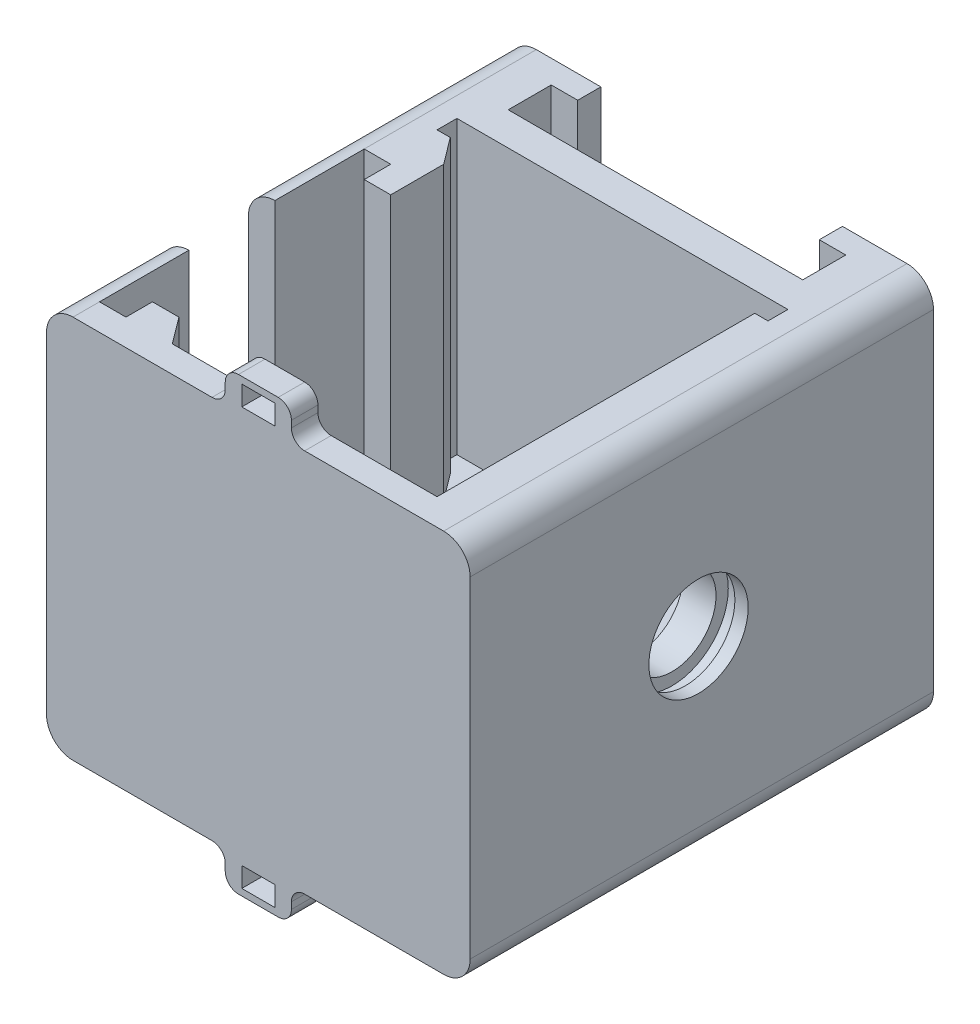
from build123d import *

# Parameters (mm, degrees)
SKETCH1_W                = 32
SKETCH1_H                = 29
BOSS_EXTRUDE1_DEPTH      = 35
FILLET1_R                = 2
SLOT_FOR_COIL_DEPTH      = 1
SLOT_FOR_COIL_DEPTH_BACK = 30
BOSS_EXTRUDE2_DEPTH      = 7
BOSS_EXTRUDE3_DEPTH      = 1.75
SKETCH5_W                = 2
SKETCH5_H                = 7
CUT_EXTRUDE2_DEPTH       = 33
CUT_EXTRUDE3_DEPTH       = 22
SKETCH7_W                = 2
SKETCH7_H                = 33
BOSS_EXTRUDE4_DEPTH      = 0.25
FILLET2_R                = 6
CUT_EXTRUDE5_DEPTH       = 4.5
SKETCH14_W               = 2.5
SKETCH14_H               = 20
CUT_EXTRUDE6_DEPTH       = 22
SKETCH16_W               = 2
SKETCH16_H               = 4
SKETCH16_H_2             = 2
BOSS_EXTRUDE5_DEPTH      = 22
BOSS_EXTRUDE6_DEPTH      = 22
SKETCH21_W               = 5
SKETCH21_H               = 2
BOSS_EXTRUDE7_DEPTH      = 2.5
SKETCH23_W               = 2.5
SKETCH23_H               = 1.5
CUT_EXTRUDE7_DEPTH       = 2
FILLET3_R                = 1


with BuildPart() as part:
    # Sketch1 → Boss-Extrude1 (new body)
    with BuildSketch(Plane.XY):
        Rectangle(SKETCH1_W, SKETCH1_H)
    extrude(amount=BOSS_EXTRUDE1_DEPTH)

    # Fillet1
    fillet1_edges = [part.edges().sort_by_distance(p)[0] for p in [
        (16, -14.5, 17.5),
        (-16, -14.5, 17.5),
        (-16, 14.5, 17.5),
        (16, 14.5, 17.5),
    ]]
    fillet(fillet1_edges, radius=FILLET1_R)

    # Sketch2 → Slot for Coil (cut, two sides)
    with BuildSketch(Plane.XZ.offset(14.5)) as slot_for_coil_sk:
        Polygon((-9.125, 0), (-9.125, 1.75), (-11.125, 1.75), (-11.125, 5), (11.125, 5), (11.125, 1.75), (9.125, 1.75), (9.125, 0), align=None)
    extrude(amount=SLOT_FOR_COIL_DEPTH, mode=Mode.SUBTRACT)
    extrude(slot_for_coil_sk.sketch, amount=-SLOT_FOR_COIL_DEPTH_BACK, mode=Mode.SUBTRACT)

    # Sketch3 → Boss-Extrude2 (add)
    with BuildSketch(Plane.XZ.offset(14.5)):
        Polygon((-9.125, 0), (-9.125, 1.75), (-11.125, 1.75), (-11.125, 5), (11.125, 5), (11.125, 1.75), (9.125, 1.75), (9.125, 0), align=None)
    extrude(amount=-BOSS_EXTRUDE2_DEPTH)

    # Sketch4 → Boss-Extrude3 (add)
    with BuildSketch(Plane(origin=(0, 0, 1.75), x_dir=(-1, 0, 0), z_dir=(0, 0, -1))):
        with BuildLine():
            Line((-9.125, 7.5), (-9.125, 6.5))
            ThreePointArc((-9.125, 6.5), (-8.875, 7), (-9.125, 7.5))
        make_face()
    boss_extrude3 = extrude(amount=BOSS_EXTRUDE3_DEPTH)

    # Mirror1: Boss-Extrude3 across plane
    add(boss_extrude3.mirror(Plane(origin=(0, 0, 0), x_dir=(0, 0, 1), z_dir=(1, 0, 0))))

    # Sketch5 → Cut-Extrude2 (cut)
    with BuildSketch(Plane(origin=(0, 0, 0), x_dir=(-1, 0, 0), z_dir=(0, 0, -1))):
        with Locations((0, -11)):
            Rectangle(SKETCH5_W, SKETCH5_H)
    extrude(amount=-CUT_EXTRUDE2_DEPTH, mode=Mode.SUBTRACT)

    # Sketch6 → Cut-Extrude3 (cut)
    with BuildSketch(Plane(origin=(0, 14.5, 0), x_dir=(1, 0, 0), z_dir=(0, 1, 0))):
        Polygon((-12.5, -7.5), (-12.5, -9), (-11.5, -9), (-11.5, -33), (11.5, -33), (11.5, -9), (12.5, -9), (12.5, -7.5), align=None)
    extrude(amount=-CUT_EXTRUDE3_DEPTH, mode=Mode.SUBTRACT)

    # Sketch7 → Boss-Extrude4 (add)
    with BuildSketch(Plane.XZ.offset(14.5)):
        with Locations((0, 16.5)):
            Rectangle(SKETCH7_W, SKETCH7_H)
    extrude(amount=-BOSS_EXTRUDE4_DEPTH)

    # Fillet2
    fillet2_edges = [part.edges().sort_by_distance(p)[0] for p in [
        (0, -14.25, 33),
    ]]
    fillet(fillet2_edges, radius=FILLET2_R)

    # Sketch9 → Cut-Revolve1 (revolve, cut)
    with BuildSketch(Plane(origin=(0, 0, 17.75), x_dir=(-1, 0, 0), z_dir=(0, 0, -1))):
        Polygon((-15, 4.25), (-14, 4.25), (-14, 3.325), (-11.5, 3.325), (-11.5, 0), (-16, 0), (-16, 3.75), (-15, 3.75), align=None)
    revolve(axis=Axis((16, 0, 17.75), (-1, 0, 0)), mode=Mode.SUBTRACT)

    # Sketch11 → Cut-Extrude5 (cut)
    with BuildSketch(Plane(origin=(-16, 0, 44), x_dir=(0, 0, -1), z_dir=(1, 0, 0))):
        with BuildLine():
            Line((24.25, 25), (24.25, 0))
            ThreePointArc((24.25, 0), (21, -3.25), (17.75, 0))
            Line((17.75, 0), (17.75, 25))
            ThreePointArc((17.75, 25), (21, 28.25), (24.25, 25))
        make_face()
    extrude(amount=CUT_EXTRUDE5_DEPTH, mode=Mode.SUBTRACT)

    # Sketch14 → Cut-Extrude6 (cut)
    with BuildSketch(Plane(origin=(0, 14.5, 0), x_dir=(1, 0, 0), z_dir=(0, 1, 0))):
        with Locations((-12.75, -23)):
            Rectangle(SKETCH14_W, SKETCH14_H)
    extrude(amount=-CUT_EXTRUDE6_DEPTH, mode=Mode.SUBTRACT)

    # Sketch16 → Boss-Extrude5 (add)
    with BuildSketch(Plane(origin=(0, 14.5, 0), x_dir=(1, 0, 0), z_dir=(0, 1, 0))):
        with Locations((-11, -13)):
            Rectangle(SKETCH16_W, SKETCH16_H)
        with Locations((-11, -32)):
            Rectangle(SKETCH16_W, SKETCH16_H_2)
    extrude(amount=-BOSS_EXTRUDE5_DEPTH)

    # Sketch20 → Boss-Extrude6 (add)
    with BuildSketch(Plane(origin=(0, 14.5, 0), x_dir=(1, 0, 0), z_dir=(0, 1, 0))):
        Polygon((-11.5, -9), (-10, -11), (-11.5, -11), align=None)
        Polygon((-10, -31), (-8.5, -33), (-10, -33), align=None)
    extrude(amount=-BOSS_EXTRUDE6_DEPTH)

    # Sketch21 → Boss-Extrude7 (add)
    with BuildSketch(Plane(origin=(0, 14.5, 0), x_dir=(-1, 0, 0), z_dir=(0, 1, 0))):
        with Locations((0, 34)):
            Rectangle(SKETCH21_W, SKETCH21_H)
    boss_extrude7 = extrude(amount=BOSS_EXTRUDE7_DEPTH)

    # Sketch23 → Cut-Extrude7 (cut)
    with BuildSketch(Plane.XY.offset(35)):
        with Locations((0, 15.75)):
            Rectangle(SKETCH23_W, SKETCH23_H)
    cut_extrude7 = extrude(amount=-CUT_EXTRUDE7_DEPTH, mode=Mode.SUBTRACT)

    # Mirror3: Boss-Extrude7, Cut-Extrude7 across plane
    add(boss_extrude7.mirror(Plane.ZX))
    add(cut_extrude7.mirror(Plane.ZX), mode=Mode.SUBTRACT)

    # Fillet3
    fillet3_edges = [part.edges().sort_by_distance(p)[0] for p in [
        (2.5, 14.5, 34),
        (-2.5, 14.5, 34),
        (2.5, 17, 34),
        (-2.5, 17, 34),
        (2.5, -17, 34),
        (-2.5, -17, 34),
        (2.5, -14.5, 34),
        (-2.5, -14.5, 34),
    ]]
    fillet(fillet3_edges, radius=FILLET3_R)


solid = part.part
